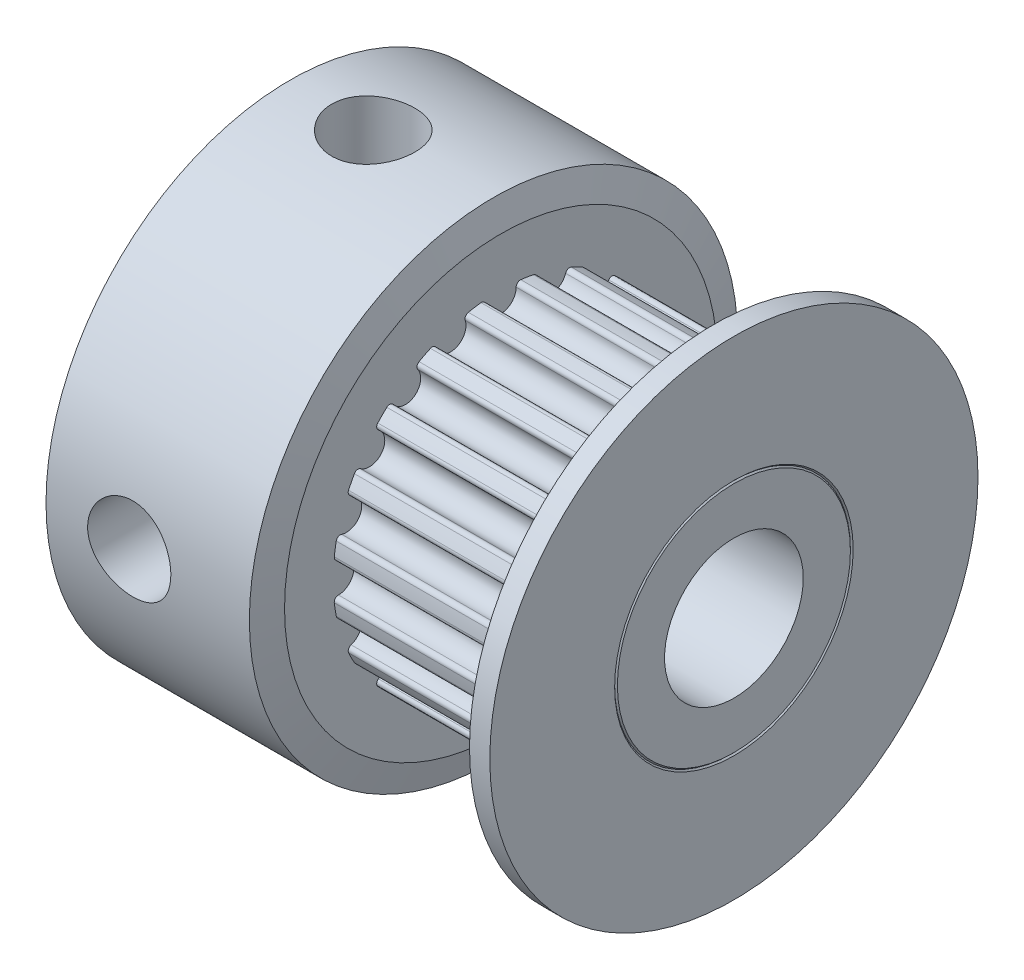
from build123d import *

# Parameters (mm, degrees)
SKETCH_2_R              = 2.5
BORE_DEPTH              = 17
SKETCH_3_R              = 0.55
F_20TOOTH_DEPTH         = 7.4
FILETS_R                = 0.15
SKETCH_4_R              = 1.5
SET_SCREW_DEPTH         = 9.8
SET_SCREW_PATTERN_COUNT = 2
SET_SCREW_PATTERN_ANGLE = 270


with BuildPart() as part:
    # Sketch1 → Body (revolve)
    with BuildSketch(Plane.XY):
        Polygon((0, 8.8), (0, 0), (16, 0), (16, 4.2), (15.95, 4.25), (16, 4.3), (16, 8.8), (15.267949192, 8.8), (15, 7.8), (15, 6.05), (7.6, 6.05), (7.6, 7.8), (7.332050808, 8.8), (6.6, 8.8), align=None)
    revolve(axis=Axis((0, 0, 0), (1, 0, 0)))

    # Sketch 2 → Bore (cut, through all)
    with BuildSketch(Plane(origin=(16, 0, 0), x_dir=(0, 0, -1), z_dir=(1, 0, 0))):
        Circle(SKETCH_2_R)
    extrude(amount=-BORE_DEPTH, mode=Mode.SUBTRACT)

    # Sketch 3 → 20tooth (cut)
    with BuildSketch(Plane(origin=(7.6, 0, 0), x_dir=(0, 0, -1), z_dir=(1, 0, 0))):
        with Locations((5.568435903, -1.809294502)):
            Circle(SKETCH_3_R)
        with Locations((4.736794502, -3.441482652)):
            Circle(SKETCH_3_R)
        with Locations((3.441482652, -4.736794502)):
            Circle(SKETCH_3_R)
        with Locations((1.809294502, -5.568435903)):
            Circle(SKETCH_3_R)
        with Locations((0, -5.855)):
            Circle(SKETCH_3_R)
        with Locations((5.855, 0)):
            Circle(SKETCH_3_R)
        with Locations((-1.809294502, -5.568435903)):
            Circle(SKETCH_3_R)
        with Locations((-3.441482652, -4.736794502)):
            Circle(SKETCH_3_R)
        with Locations((-4.736794502, -3.441482652)):
            Circle(SKETCH_3_R)
        with Locations((-5.568435903, -1.809294502)):
            Circle(SKETCH_3_R)
        with Locations((-5.855, 0)):
            Circle(SKETCH_3_R)
        with Locations((-5.568435903, 1.809294502)):
            Circle(SKETCH_3_R)
        with Locations((-4.736794502, 3.441482652)):
            Circle(SKETCH_3_R)
        with Locations((-3.441482652, 4.736794502)):
            Circle(SKETCH_3_R)
        with Locations((-1.809294502, 5.568435903)):
            Circle(SKETCH_3_R)
        with Locations((0, 5.855)):
            Circle(SKETCH_3_R)
        with Locations((1.809294502, 5.568435903)):
            Circle(SKETCH_3_R)
        with Locations((3.441482652, 4.736794502)):
            Circle(SKETCH_3_R)
        with Locations((4.736794502, 3.441482652)):
            Circle(SKETCH_3_R)
        with Locations((5.568435903, 1.809294502)):
            Circle(SKETCH_3_R)
    extrude(amount=F_20TOOTH_DEPTH, mode=Mode.SUBTRACT)

    # Filets
    filets_edges = [part.edges().sort_by_distance(p)[0] for p in [
        (11.3, -4.569294161, 3.965356335),
        (11.3, -5.18326753, 3.120294491),
        (11.3, -3.120294491, 5.18326753),
        (11.3, -3.965356335, 4.569294161),
        (11.3, -1.365858655, 5.893804386),
        (11.3, -2.359288434, 5.571019483),
        (11.3, 0.522276943, 6.027414603),
        (11.3, -0.522276943, 6.027414603),
        (11.3, 2.359288434, 5.571019483),
        (11.3, 1.365858655, 5.893804386),
        (11.3, 3.965356335, 4.569294161),
        (11.3, 3.120294491, 5.18326753),
        (11.3, 5.18326753, 3.120294491),
        (11.3, 4.569294161, 3.965356335),
        (11.3, 5.893804386, 1.365858655),
        (11.3, 5.571019483, 2.359288434),
        (11.3, 6.027414603, -0.522276943),
        (11.3, 6.027414603, 0.522276943),
        (11.3, 5.571019483, -2.359288434),
        (11.3, 5.893804386, -1.365858655),
        (11.3, 4.569294161, -3.965356335),
        (11.3, 5.18326753, -3.120294491),
        (11.3, 3.120294491, -5.18326753),
        (11.3, 3.965356335, -4.569294161),
        (11.3, 1.365858655, -5.893804386),
        (11.3, 2.359288434, -5.571019483),
        (11.3, -2.359288434, -5.571019483),
        (11.3, -1.365858655, -5.893804386),
        (11.3, -3.965356335, -4.569294161),
        (11.3, -3.120294491, -5.18326753),
        (11.3, -5.18326753, -3.120294491),
        (11.3, -4.569294161, -3.965356335),
        (11.3, -5.893804386, -1.365858655),
        (11.3, -5.571019483, -2.359288434),
        (11.3, -6.027414603, 0.522276943),
        (11.3, -6.027414603, -0.522276943),
        (11.3, -0.522276943, -6.027414603),
        (11.3, 0.522276943, -6.027414603),
        (11.3, -5.571019483, 2.359288434),
        (11.3, -5.893804386, 1.365858655),
    ]]
    fillet(filets_edges, radius=FILETS_R)

    # Sketch 4 → Set screw (cut, through all)
    with BuildSketch(Plane.XY):
        with Locations((3, 0)):
            Circle(SKETCH_4_R)
    set_screw = extrude(amount=SET_SCREW_DEPTH, mode=Mode.SUBTRACT)

    # Set screw pattern: Set screw ×2 about axis
    set_screw_pattern_axis = Axis((0, 0, 0), (1, 0, 0))
    for i in range(1, SET_SCREW_PATTERN_COUNT):
        add(set_screw.rotate(set_screw_pattern_axis, i * SET_SCREW_PATTERN_ANGLE / (SET_SCREW_PATTERN_COUNT - 1)), mode=Mode.SUBTRACT)


solid = part.part
